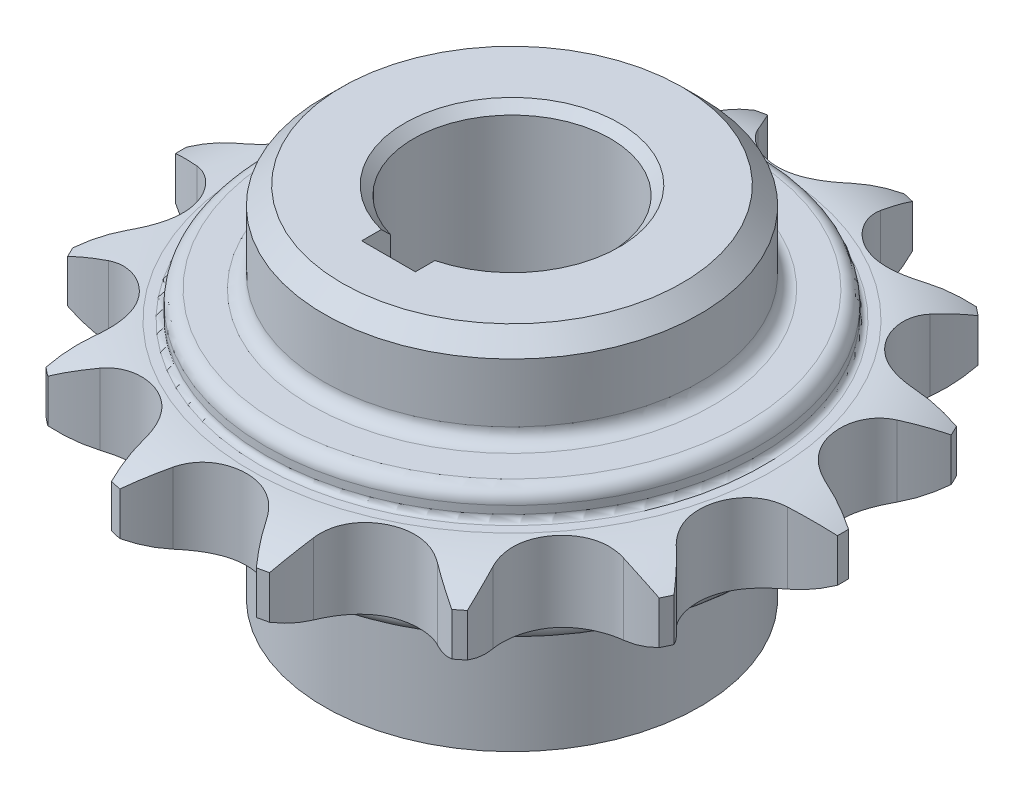
from build123d import *

# Parameters (mm, degrees)
EXTRUDE_1_DEPTH          = 8.93
PATTERN_CIRCULAR_1_COUNT = 14
SKETCH_4_R               = 27.5
EXTRUDE_3_DEPTH          = 3
SKETCH_3_R               = 27.5
EXTRUDE_2_DEPTH          = 3
SKETCH_5_R               = 21
EXTRUDE_4_DEPTH          = 10.07
FILLET_1_R               = 0.635
FILLET_2_R               = 1.5
CHAMFER_1_SIZE           = 2
SKETCH_8_R               = 21
EXTRUDE_5_DEPTH          = 15
SKETCH_6_R               = 11
CUT_EXTRUDE_3_DEPTH      = 40
CHAMFER_2_SIZE           = 1
CUT_EXTRUDE_4_REACH      = 27
CUT_EXTRUDE_5_DEPTH      = 15


with BuildPart() as part:
    # 草图1 → 凸台-拉伸1 (new body)
    with BuildSketch(Plane(origin=(0, 0, 0), x_dir=(1, 0, 0), z_dir=(0, 1, 0))):
        with BuildLine():
            Line((0, 29.67085), (0, 0))
            Line((0, 0), (12.873699341, 26.732512134))
            ThreePointArc((12.873699341, 26.732512134), (10.51956913, 28.758404993), (9.493778992, 31.68994478))
            ThreePointArc((9.493778992, 31.68994478), (9.248307253, 33.823053422), (8.834109534, 35.929911059))
            ThreePointArc((8.834109534, 35.929911059), (8.233274556, 36.072332751), (7.630146491, 36.204707767))
            ThreePointArc((7.630146491, 36.204707767), (6.342835971, 34.486208283), (5.196152423, 32.67085))
            ThreePointArc((5.196152423, 32.67085), (3, 30.474697577), (0, 29.67085))
        make_face()
    extrude_1 = extrude(amount=EXTRUDE_1_DEPTH)

    # 阵列(圆周)1: 凸台-拉伸1 ×14 about axis
    pattern_circular_1_axis = Axis((0, 0, 0), (0, 1, 0))
    for i in range(1, PATTERN_CIRCULAR_1_COUNT):
        add(extrude_1.rotate(pattern_circular_1_axis, i * 360 / PATTERN_CIRCULAR_1_COUNT))

    # 草图2 → 切除-旋转1 (revolve, cut)
    with BuildSketch(Plane.XY):
        with BuildLine():
            Line((36.994847478, 8.93), (29.167651401, 8.93))
            ThreePointArc((29.167651401, 8.93), (33.21499814, 8.405394437), (36.994847478, 6.86625))
            Line((36.994847478, 6.86625), (36.994847478, 2.06375))
            ThreePointArc((36.994847478, 2.06375), (33.21499814, 0.524605563), (29.167651401, 0))
            Line((29.167651401, 0), (36.994847478, 0))
            Line((36.994847478, 0), (43.746655318, 0))
            Line((43.746655318, 0), (43.746655318, 8.93))
            Line((43.746655318, 8.93), (36.994847478, 8.93))
        make_face()
    revolve(axis=Axis((0, 0, 0), (0, 1, 0)), mode=Mode.SUBTRACT)

    # 草图4 → 凸台-拉伸3 (add)
    with BuildSketch(Plane.XZ):
        Circle(SKETCH_4_R)
    extrude(amount=EXTRUDE_3_DEPTH)

    # 草图3 → 凸台-拉伸2 (add)
    with BuildSketch(Plane(origin=(0, 8.93, 0), x_dir=(1, 0, 0), z_dir=(0, 1, 0))):
        Circle(SKETCH_3_R)
    extrude(amount=EXTRUDE_2_DEPTH)

    # 草图5 → 凸台-拉伸4 (add)
    with BuildSketch(Plane(origin=(0, 11.93, 0), x_dir=(1, 0, 0), z_dir=(0, 1, 0))):
        Circle(SKETCH_5_R)
    extrude(amount=EXTRUDE_4_DEPTH)

    # 圆角1
    fillet_1_edges = [part.edges().sort_by_distance(p)[0] for p in [
        (-27.5, 0, 0),
        (-27.5, 8.93, 0),
    ]]
    fillet(fillet_1_edges, radius=FILLET_1_R)

    # 圆角2
    fillet_2_edges = [part.edges().sort_by_distance(p)[0] for p in [
        (-27.5, -3, 0),
        (-27.5, 11.93, 0),
        (-21, 11.93, 0),
    ]]
    fillet(fillet_2_edges, radius=FILLET_2_R)

    # 倒角1
    chamfer_1_edges = [part.edges().sort_by_distance(p)[0] for p in [
        (-21, 22, 0),
    ]]
    chamfer(chamfer_1_edges, length=CHAMFER_1_SIZE)

    # 草图8 → 凸台-拉伸5 (add)
    with BuildSketch(Plane.XZ.offset(3)):
        Circle(SKETCH_8_R)
    extrude(amount=EXTRUDE_5_DEPTH)

    # 草图6 → 切除-拉伸3 (cut)
    with BuildSketch(Plane(origin=(0, 22, 0), x_dir=(1, 0, 0), z_dir=(0, 1, 0))):
        Circle(SKETCH_6_R)
    extrude(amount=-CUT_EXTRUDE_3_DEPTH, mode=Mode.SUBTRACT)

    # 倒角2
    chamfer_2_edges = [part.edges().sort_by_distance(p)[0] for p in [
        (-11, -18, 0),
        (-11, 22, 0),
    ]]
    chamfer(chamfer_2_edges, length=CHAMFER_2_SIZE)

    # 草图7 → 切除-拉伸4 (cut, up to next)
    with BuildSketch(Plane.XZ.offset(3), mode=Mode.PRIVATE) as cut_extrude_4_sk1:
        with BuildLine():
            Line((-3, 10.583005244), (-3, 13.8))
            Line((-3, 13.8), (3, 13.8))
            Line((3, 13.8), (3, 10.583005244))
            ThreePointArc((3, 10.583005244), (0, 11), (-3, 10.583005244))
        make_face()
    cut_extrude_4_tool1 = extrude(cut_extrude_4_sk1.sketch, amount=-CUT_EXTRUDE_4_REACH, mode=Mode.PRIVATE) & part.part
    add(cut_extrude_4_tool1.solids().sort_by_distance((0, -3, 12.328421))[0], mode=Mode.SUBTRACT)

    # 草图7<3> → 切除-拉伸5 (cut)
    with BuildSketch(Plane.XZ.offset(3)):
        with BuildLine():
            Line((-3, 10.583005244), (-3, 13.8))
            Line((-3, 13.8), (3, 13.8))
            Line((3, 13.8), (3, 10.583005244))
            ThreePointArc((3, 10.583005244), (0, 11), (-3, 10.583005244))
        make_face()
    extrude(amount=CUT_EXTRUDE_5_DEPTH, mode=Mode.SUBTRACT)


solid = part.part
